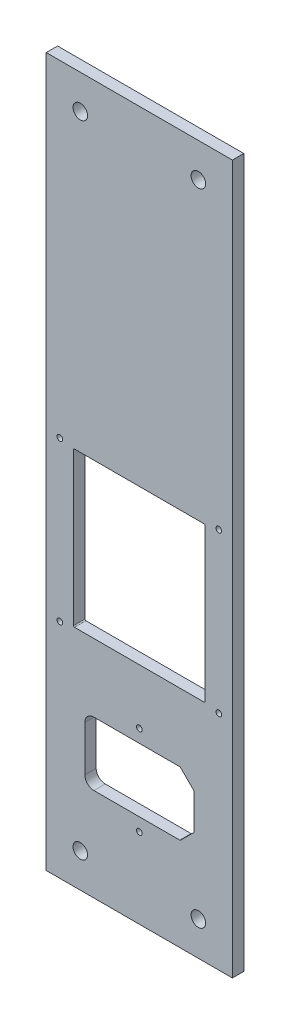
from build123d import *

# Parameters (mm, degrees)
SKETCH1_W                = 82
SKETCH1_H                = 312
BOSS_EXTRUDE1_DEPTH      = 5
SKETCH2_R                = 1.25
SKETCH2_W                = 48
SKETCH2_H                = 28
CUT_EXTRUDE1_DEPTH       = 10
CHAMFER1_SIZE            = 6
FILLET1_R                = 4
SKETCH3_W                = 58
SKETCH3_H                = 68
CUT_EXTRUDE2_DEPTH       = 6
M3X0_5_TAPPED_HOLE1_D    = 2.5
FILLET2_R                = 0.5
M6_CLEARANCE_HOLE1_D     = 6.4
M6_CLEARANCE_HOLE1_DEPTH = 5
M6_CLEARANCE_HOLE1_TIP   = 1.922753981


with BuildPart() as part:
    # Sketch1 → Boss-Extrude1 (new body)
    with BuildSketch(Plane.XY):
        Rectangle(SKETCH1_W, SKETCH1_H)
    extrude(amount=BOSS_EXTRUDE1_DEPTH)

    # Sketch2 → Cut-Extrude1 (cut)
    with BuildSketch(Plane.XY.offset(5)):
        with Locations((0, -81.25)):
            Circle(SKETCH2_R)
        with Locations((0, -120.75)):
            Circle(SKETCH2_R)
        with Locations((0, -101)):
            Rectangle(SKETCH2_W, SKETCH2_H)
    extrude(amount=-CUT_EXTRUDE1_DEPTH, mode=Mode.SUBTRACT)

    # Chamfer1
    chamfer1_edges = [part.edges().sort_by_distance(p)[0] for p in [
        (24, -87, 2.5),
        (24, -115, 2.5),
    ]]
    chamfer(chamfer1_edges, length=CHAMFER1_SIZE)

    # Fillet1
    fillet1_edges = [part.edges().sort_by_distance(p)[0] for p in [
        (-24, -115, 2.5),
        (-24, -87, 2.5),
    ]]
    fillet(fillet1_edges, radius=FILLET1_R)

    # Sketch3 → Cut-Extrude2 (cut, through all)
    with BuildSketch(Plane.XY.offset(5)):
        with Locations((0, -23)):
            Rectangle(SKETCH3_W, SKETCH3_H)
    extrude(amount=-CUT_EXTRUDE2_DEPTH, mode=Mode.SUBTRACT)

    # M3x0.5 Tapped Hole1 (through all)
    with Locations(Plane.XY.offset(5)):
        with Locations((-35, 12), (35, 12), (35, -58), (-35, -58)):
            Hole(M3X0_5_TAPPED_HOLE1_D / 2)

    # Fillet2
    fillet2_edges = [part.edges().sort_by_distance(p)[0] for p in [
        (24, -93, 2.5),
        (24, -109, 2.5),
        (18, -115, 2.5),
        (18, -87, 2.5),
        (29, 11, 2.5),
        (29, -57, 2.5),
        (-29, -57, 2.5),
        (-29, 11, 2.5),
    ]]
    fillet(fillet2_edges, radius=FILLET2_R)

    # M6 Clearance Hole1
    with Locations(Plane.XY.offset(5)):
        with Locations((-26, 141), (26, 141), (-26, -141), (26, -141)):
            Hole(M6_CLEARANCE_HOLE1_D / 2, depth=M6_CLEARANCE_HOLE1_DEPTH)
            with Locations((0, 0, -(M6_CLEARANCE_HOLE1_DEPTH + M6_CLEARANCE_HOLE1_TIP / 2))):  # 118° drill point
                Cone(0, M6_CLEARANCE_HOLE1_D / 2, M6_CLEARANCE_HOLE1_TIP, mode=Mode.SUBTRACT)


solid = part.part
